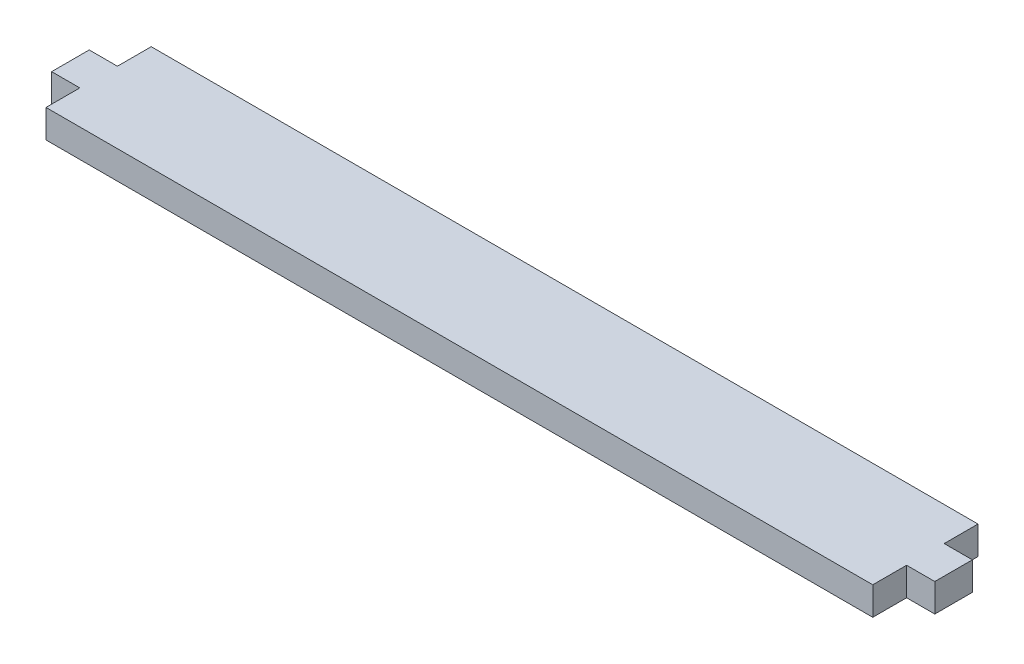
from build123d import *

# Parameters (mm, degrees)
SKETCH1_W           = 279.4
SKETCH1_H           = 35.56
BOSS_EXTRUDE1_DEPTH = 9.525
SKETCH2_W           = 12.7
SKETCH2_H           = 9.525
BOSS_EXTRUDE2_DEPTH = 9.525


with BuildPart() as part:
    # Sketch1 → Boss-Extrude1 (new body)
    with BuildSketch(Plane(origin=(0, 0, 0), x_dir=(1, 0, 0), z_dir=(0, 1, 0))):
        Rectangle(SKETCH1_W, SKETCH1_H)
    extrude(amount=BOSS_EXTRUDE1_DEPTH)

    # Sketch2 → Boss-Extrude2 (add)
    with BuildSketch(Plane(origin=(139.7, 0, 0), x_dir=(0, 0, -1), z_dir=(1, 0, 0))):
        with Locations((0, 4.7625)):
            Rectangle(SKETCH2_W, SKETCH2_H)
    boss_extrude2 = extrude(amount=BOSS_EXTRUDE2_DEPTH)

    # Mirror1: Boss-Extrude2 across plane
    add(boss_extrude2.mirror(Plane(origin=(0, 0, 0), x_dir=(0, 0, 1), z_dir=(1, 0, 0))))


solid = part.part
